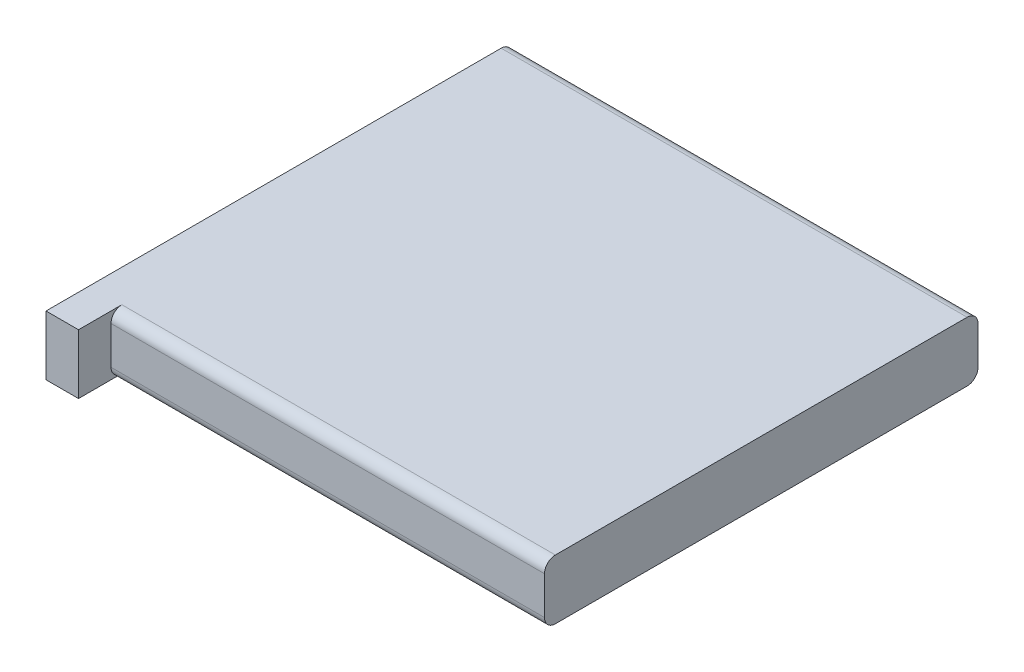
from build123d import *

# Parameters (mm, degrees)
SKETCH1_W                = 43
SKETCH1_H                = 40
BOSS_EXTRUDE1_DEPTH      = 5.5
FILLET1_R                = 1
SKETCH2_W                = 3
SKETCH2_H                = 5.5
BOSS_EXTRUDE2_DEPTH      = 3
BOSS_EXTRUDE2_DEPTH_BACK = 3


with BuildPart() as part:
    # Sketch1 → Boss-Extrude1 (new body)
    with BuildSketch(Plane(origin=(0, 0, 0), x_dir=(1, 0, 0), z_dir=(0, 1, 0))):
        Rectangle(SKETCH1_W, SKETCH1_H)
    extrude(amount=BOSS_EXTRUDE1_DEPTH)

    # Fillet1
    fillet1_edges = [part.edges().sort_by_distance(p)[0] for p in [
        (0, 5.5, -20),
        (0, 0, -20),
        (0, 0, 20),
        (0, 5.5, 20),
    ]]
    fillet(fillet1_edges, radius=FILLET1_R)

    # Sketch2 → Boss-Extrude2 (add, two sides)
    with BuildSketch(Plane.XY.offset(20)) as boss_extrude2_sk:
        with Locations((-20, 2.75)):
            Rectangle(SKETCH2_W, SKETCH2_H)
    extrude(amount=BOSS_EXTRUDE2_DEPTH)
    extrude(boss_extrude2_sk.sketch, amount=-BOSS_EXTRUDE2_DEPTH_BACK)


solid = part.part
